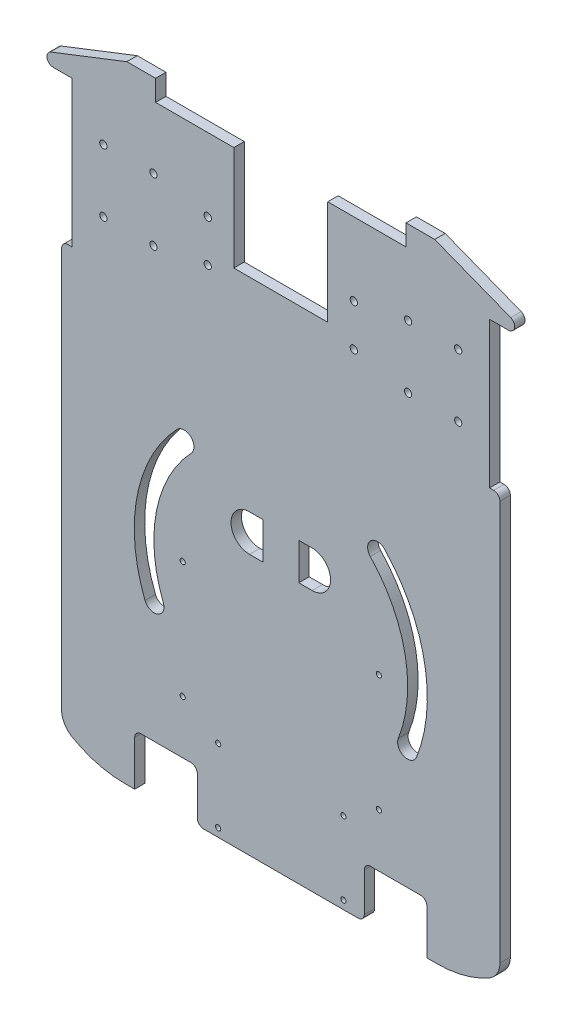
from build123d import *

# Parameters (mm, degrees)
SKETCH_1_W             = 300
SKETCH_1_H             = 300
EXTRUDE_2_DEPTH        = 5
SKETCH_4_W             = 45
SKETCH_4_H             = 60
CUT_EXTRUDE_3_DEPTH    = 5
SKETCH_5_OUTSIDE_W     = 386.858
SKETCH_5_OUTSIDE_H     = 386.858
SKETCH_5_OUTSIDE_W_2   = 250
SKETCH_5_OUTSIDE_H_2   = 300
CUT_EXTRUDE_4_DEPTH    = 5
SKETCH_6_R             = 1.75
SKETCH_6_R_2           = 1.25
CUT_EXTRUDE_5_DEPTH    = 5
SKETCH_7_W             = 50
SKETCH_7_H             = 70
CUT_EXTRUDE_6_DEPTH    = 10
SKETCH_8_W             = 30
SKETCH_8_H             = 24.494897428
SKETCH_8_W_2           = 120
SKETCH_8_H_2           = 10
CUT_EXTRUDE_7_DEPTH    = 10
FILLET_1_R             = 3
HOLE_WIZARD_M3_1_D     = 2.5
HOLE_WIZARD_M3_1_DEPTH = 10
HOLE_WIZARD_M3_1_TIP   = 0.751075774


with BuildPart() as part:
    # 草图1 → 凸台-拉伸2 (new body)
    with BuildSketch(Plane.XY):
        Rectangle(SKETCH_1_W, SKETCH_1_H)
    extrude(amount=EXTRUDE_2_DEPTH)

    # 草图4 → 切除-拉伸3 (cut)
    with BuildSketch(Plane.XY.offset(5)):
        with Locations((0, 120)):
            Rectangle(SKETCH_4_W, SKETCH_4_H)
    extrude(amount=-CUT_EXTRUDE_3_DEPTH, mode=Mode.SUBTRACT)

    # 草图5 outside → 切除-拉伸4 (cut)
    with BuildSketch(Plane.XY.offset(5)):
        Rectangle(SKETCH_5_OUTSIDE_W, SKETCH_5_OUTSIDE_H)
        Rectangle(SKETCH_5_OUTSIDE_W_2, SKETCH_5_OUTSIDE_H_2, mode=Mode.SUBTRACT)
    extrude(amount=-CUT_EXTRUDE_4_DEPTH, mode=Mode.SUBTRACT)

    # 草图6 → 切除-拉伸5 (cut)
    with BuildSketch(Plane.XY.offset(5)):
        with Locations((-85, 110)):
            Circle(SKETCH_6_R)
        with Locations((-61, 110)):
            Circle(SKETCH_6_R)
        with Locations((-61, 80)):
            Circle(SKETCH_6_R)
        with Locations((-85, 80)):
            Circle(SKETCH_6_R)
        with Locations((85, 80)):
            Circle(SKETCH_6_R)
        with Locations((61, 80)):
            Circle(SKETCH_6_R)
        with Locations((61, 110)):
            Circle(SKETCH_6_R)
        with Locations((85, 110)):
            Circle(SKETCH_6_R)
        with Locations((-47, -100)):
            Circle(SKETCH_6_R_2)
        with Locations((-47, -44)):
            Circle(SKETCH_6_R_2)
        with Locations((47, -44)):
            Circle(SKETCH_6_R_2)
        with Locations((47, -100)):
            Circle(SKETCH_6_R_2)
        with Locations((-35, 105)):
            Circle(SKETCH_6_R)
        with Locations((-35, 85)):
            Circle(SKETCH_6_R)
        with Locations((35, 85)):
            Circle(SKETCH_6_R)
        with Locations((35, 105)):
            Circle(SKETCH_6_R)
    extrude(amount=-CUT_EXTRUDE_5_DEPTH, mode=Mode.SUBTRACT)

    # 草图7 → 切除-拉伸6 (cut)
    with BuildSketch(Plane.XY.offset(5)):
        with Locations((-125, 95)):
            Rectangle(SKETCH_7_W, SKETCH_7_H)
        with Locations((125, 95)):
            Rectangle(SKETCH_7_W, SKETCH_7_H)
    extrude(amount=-CUT_EXTRUDE_6_DEPTH, mode=Mode.SUBTRACT)

    # 草图8 → 切除-拉伸7 (cut)
    with BuildSketch(Plane.XY.offset(5)):
        Polygon((-125, 130), (-73.75, 150), (-125, 150), align=None)
        Polygon((125, 130), (73.75, 150), (125, 150), align=None)
        with BuildLine():
            Line((75, -150), (125, -150))
            Line((125, -150), (125, 60))
            Line((125, 60), (105, 60))
            Line((105, 60), (105, -134.641016151))
            ThreePointArc((105, -134.641016151), (103.660254038, -139.641016151), (100, -143.301270189))
            ThreePointArc((100, -143.301270189), (87.940952255, -148.296291314), (75, -150))
        make_face()
        with Locations((-55, -137.752551286)):
            Rectangle(SKETCH_8_W, SKETCH_8_H)
        with Locations((55, -137.752551286)):
            Rectangle(SKETCH_8_W, SKETCH_8_H)
        with Locations((0, 145)):
            Rectangle(SKETCH_8_W_2, SKETCH_8_H_2)
        with BuildLine():
            Line((-105, 60), (-105, -134.641016151))
            ThreePointArc((-105, -134.641016151), (-103.660254038, -139.641016151), (-100, -143.301270189))
            ThreePointArc((-100, -143.301270189), (-87.940952255, -148.296291314), (-75, -150))
            Line((-75, -150), (-125, -150))
            Line((-125, -150), (-125, 60))
            Line((-125, 60), (-105, 60))
        make_face()
        with BuildLine():
            Line((-15.032646415, -7.416105565), (-8.618717278, -7.416105565))
            Line((-8.618717278, -7.416105565), (-8.618717278, -25.054410692))
            Line((-8.618717278, -25.054410692), (-15.032646415, -25.054410692))
            ThreePointArc((-15.032646415, -25.054410692), (-23.851798978, -16.235258128), (-15.032646415, -7.416105565))
        make_face()
        with BuildLine():
            Line((8.618717278, -25.054410692), (15.032646415, -25.054410692))
            ThreePointArc((15.032646415, -25.054410692), (23.851798978, -16.235258128), (15.032646415, -7.416105565))
            Line((15.032646415, -7.416105565), (8.618717278, -7.416105565))
            Line((8.618717278, -7.416105565), (8.618717278, -25.054410692))
        make_face()
        with BuildLine():
            ThreePointArc((-49.706822203, 9.446585999), (-68.824680462, -27.637553869), (-65.047087709, -69.188194384))
            ThreePointArc((-65.047087709, -69.188194384), (-58.959639066, -71.844151136), (-56.303682313, -65.756702493))
            ThreePointArc((-56.303682313, -65.756702493), (-59.605793483, -29.435996915), (-42.894279713, 2.980401704))
            ThreePointArc((-42.894279713, 2.980401704), (-43.06745881, 9.619765097), (-49.706822203, 9.446585999))
        make_face()
        with BuildLine():
            ThreePointArc((49.706822203, 9.446585999), (68.824680462, -27.637553869), (65.047087709, -69.188194384))
            ThreePointArc((65.047087709, -69.188194384), (58.959639066, -71.844151136), (56.303682313, -65.756702493))
            ThreePointArc((56.303682313, -65.756702493), (59.605793483, -29.435996915), (42.894279713, 2.980401704))
            ThreePointArc((42.894279713, 2.980401704), (43.06745881, 9.619765097), (49.706822203, 9.446585999))
        make_face()
    extrude(amount=-CUT_EXTRUDE_7_DEPTH, mode=Mode.SUBTRACT)

    # 圆角1
    fillet_1_edges = [part.edges().sort_by_distance(p)[0] for p in [
        (125, 130, 2.5),
        (-125, 130, 2.5),
        (-105, 60, 2.5),
        (105, 60, 2.5),
        (-40, -125.505102572, 2.5),
        (-40, -150, 2.5),
        (-70, -125.505102572, 2.5),
        (40, -150, 2.5),
        (40, -125.505102572, 2.5),
        (70, -125.505102572, 2.5),
    ]]
    fillet(fillet_1_edges, radius=FILLET_1_R)

    # M3 螺纹孔1
    with Locations(Plane.XY.offset(5)):
        with Locations((-30, -146), (30, -146), (30, -111), (-30, -111)):
            Hole(HOLE_WIZARD_M3_1_D / 2, depth=HOLE_WIZARD_M3_1_DEPTH)
            with Locations((0, 0, -(HOLE_WIZARD_M3_1_DEPTH + HOLE_WIZARD_M3_1_TIP / 2))):  # 118° drill point
                Cone(0, HOLE_WIZARD_M3_1_D / 2, HOLE_WIZARD_M3_1_TIP, mode=Mode.SUBTRACT)


solid = part.part
